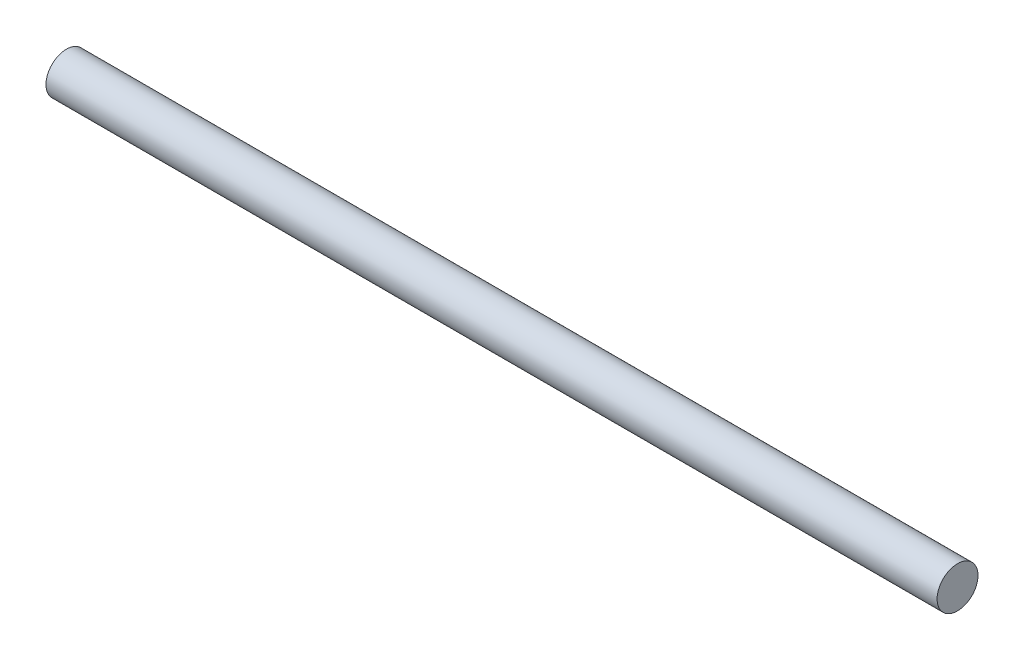
from build123d import *

# Parameters (mm, degrees)
SKETCH1_R           = 2.2
BOSS_EXTRUDE1_DEPTH = 47.9


with BuildPart() as part:
    # Sketch1 → Boss-Extrude1 (new body, symmetric)
    with BuildSketch(Plane(origin=(0, 0, 0), x_dir=(0, 0, -1), z_dir=(1, 0, 0))):
        Circle(SKETCH1_R)
    extrude(amount=BOSS_EXTRUDE1_DEPTH, both=True)


solid = part.part
